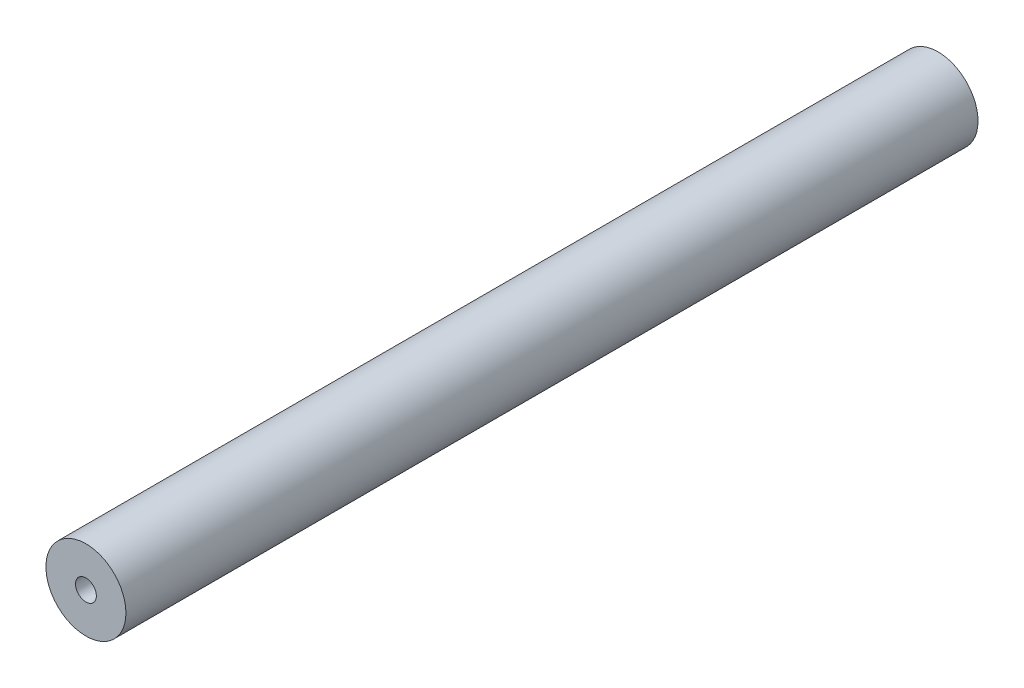
from build123d import *

# Parameters (mm, degrees)
SKETCH2_R           = 115
SKETCH2_R_2         = 30
BOSS_EXTRUDE1_DEPTH = 2450
SCALE1_SCALE        = 0.1


with BuildPart() as part:
    # Sketch2 → Boss-Extrude1 (new body)
    with BuildSketch(Plane.XY):
        Circle(SKETCH2_R)
        Circle(SKETCH2_R_2, mode=Mode.SUBTRACT)
    extrude(amount=BOSS_EXTRUDE1_DEPTH)


with BuildPart() as part_1:
    # Scale1: scaled about (0, 0, 1225)
    add(part.part.scale(SCALE1_SCALE).moved(Location((0, 0, 1102.5))))


solid = part_1.part
